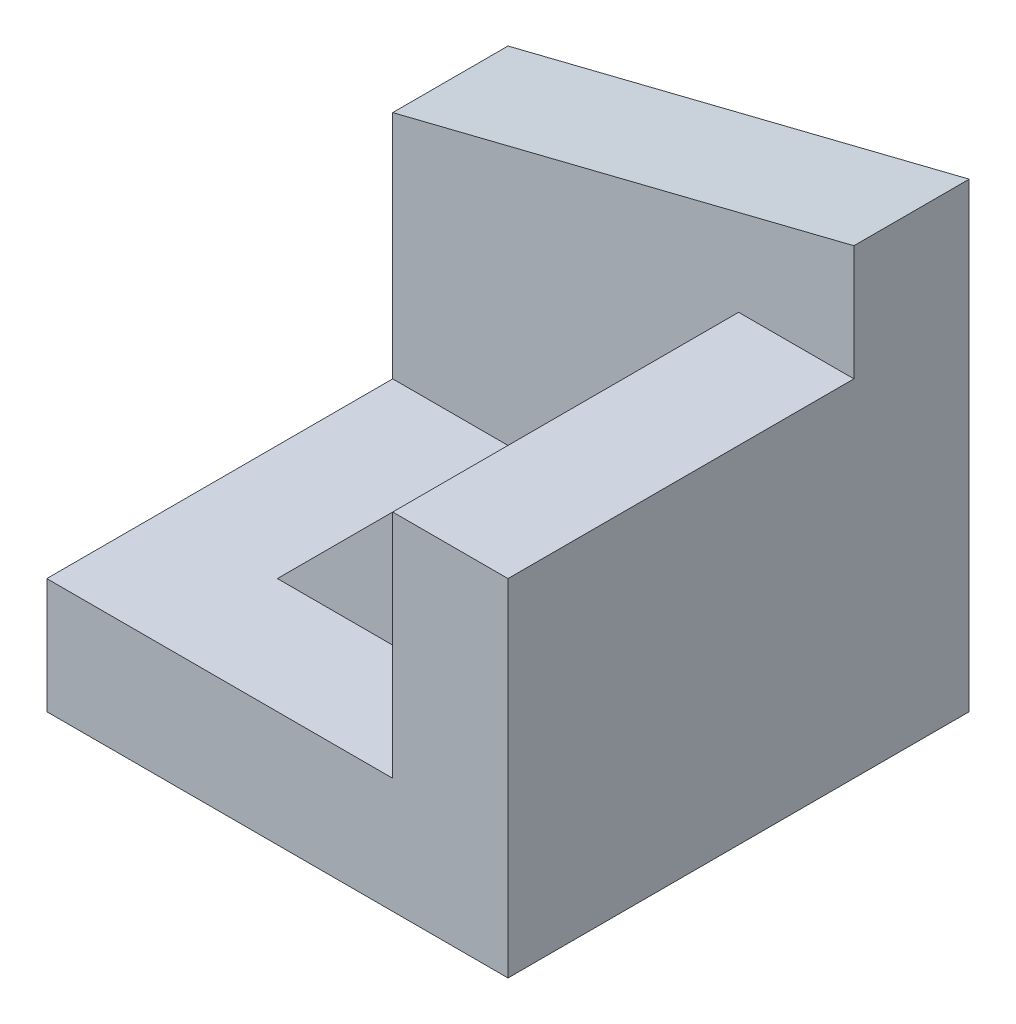
from build123d import *

# Parameters (mm, degrees)
SKETCH1_W           = 40
SKETCH1_H           = 40
BOSS_EXTRUDE1_DEPTH = 40
CUT_EXTRUDE1_DEPTH  = 40
SKETCH3_W           = 30
SKETCH3_H           = 10
CUT_EXTRUDE2_DEPTH  = 40
CUT_EXTRUDE6_DEPTH  = 30
SKETCH6_W           = 30
SKETCH6_H           = 20
CUT_EXTRUDE7_DEPTH  = 30
CUT_EXTRUDE9_DEPTH  = 10


with BuildPart() as part:
    # Sketch1 → Boss-Extrude1 (new body)
    with BuildSketch(Plane.XY):
        with Locations((20, 20)):
            Rectangle(SKETCH1_W, SKETCH1_H)
    extrude(amount=BOSS_EXTRUDE1_DEPTH)

    # Sketch2 → Cut-Extrude1 (cut)
    with BuildSketch(Plane.XY.offset(40)):
        Polygon((40, 40), (0, 30), (0, 40), align=None)
    extrude(amount=-CUT_EXTRUDE1_DEPTH, mode=Mode.SUBTRACT)

    # Sketch3 → Cut-Extrude2 (cut)
    with BuildSketch(Plane(origin=(40, 0, 0), x_dir=(0, 0, -1), z_dir=(1, 0, 0))):
        with Locations((-25, 35)):
            Rectangle(SKETCH3_W, SKETCH3_H)
    extrude(amount=-CUT_EXTRUDE2_DEPTH, mode=Mode.SUBTRACT)

    # Sketch4 → Cut-Extrude6 (cut)
    with BuildSketch(Plane.XY.offset(40)):
        Polygon((30, 30), (10, 30), (10, 10), align=None)
    extrude(amount=-CUT_EXTRUDE6_DEPTH, mode=Mode.SUBTRACT)

    # Sketch6 → Cut-Extrude7 (cut)
    with BuildSketch(Plane(origin=(10, 0, 0), x_dir=(0, 0, -1), z_dir=(1, 0, 0))):
        with Locations((-25, 20)):
            Rectangle(SKETCH6_W, SKETCH6_H)
    extrude(amount=-CUT_EXTRUDE7_DEPTH, mode=Mode.SUBTRACT)

    # Sketch7 → Cut-Extrude9 (cut)
    with BuildSketch(Plane.XY.offset(40)):
        Polygon((30, 30), (30, 10), (10, 10), align=None)
    extrude(amount=-CUT_EXTRUDE9_DEPTH, mode=Mode.SUBTRACT)


solid = part.part
